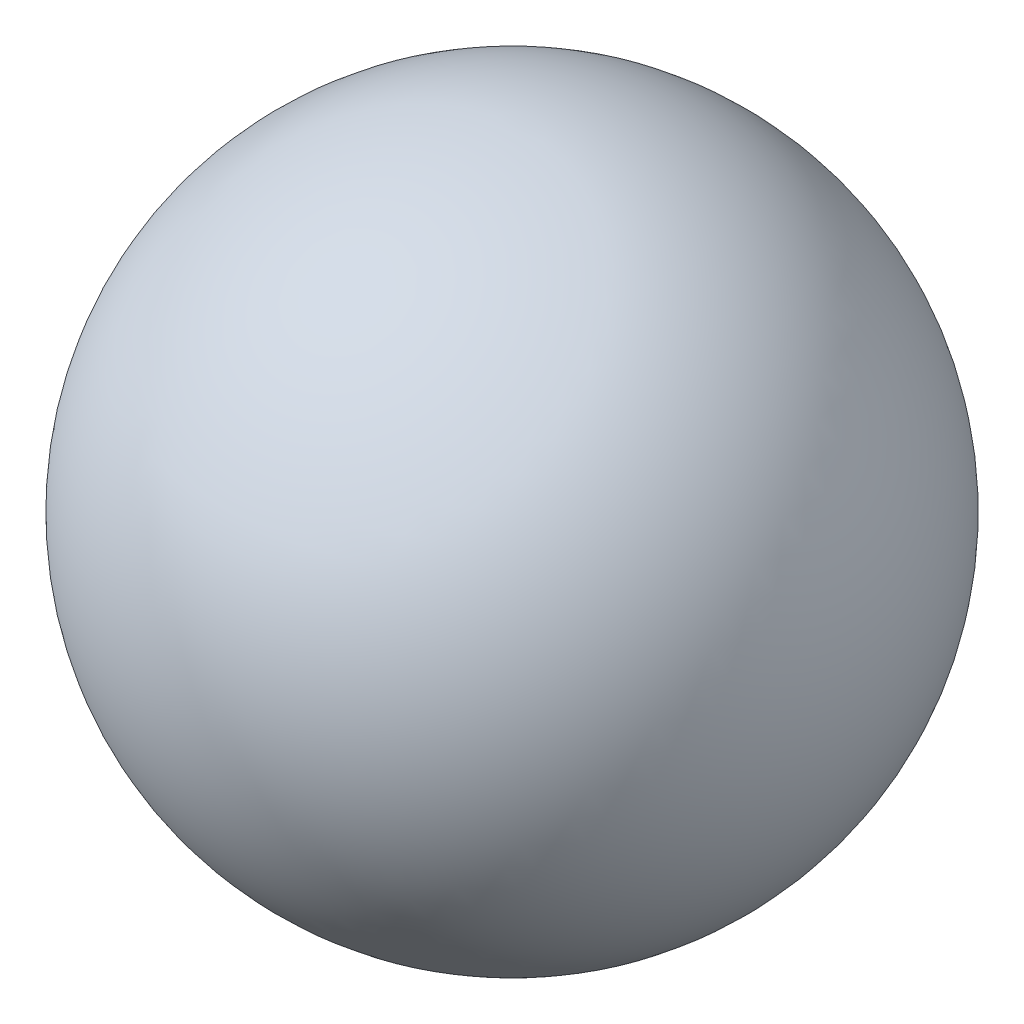
from build123d import *


with BuildPart() as part:
    # Esquisse1 → Révolution3 (revolve)
    with BuildSketch(Plane.XY):
        with BuildLine():
            Line((0, 11.11), (0, -11.11))
            ThreePointArc((0, -11.11), (-11.11, 0), (0, 11.11))
        make_face()
    revolve(axis=Axis((0, 11.11, 0), (0, -1, 0)))


solid = part.part
